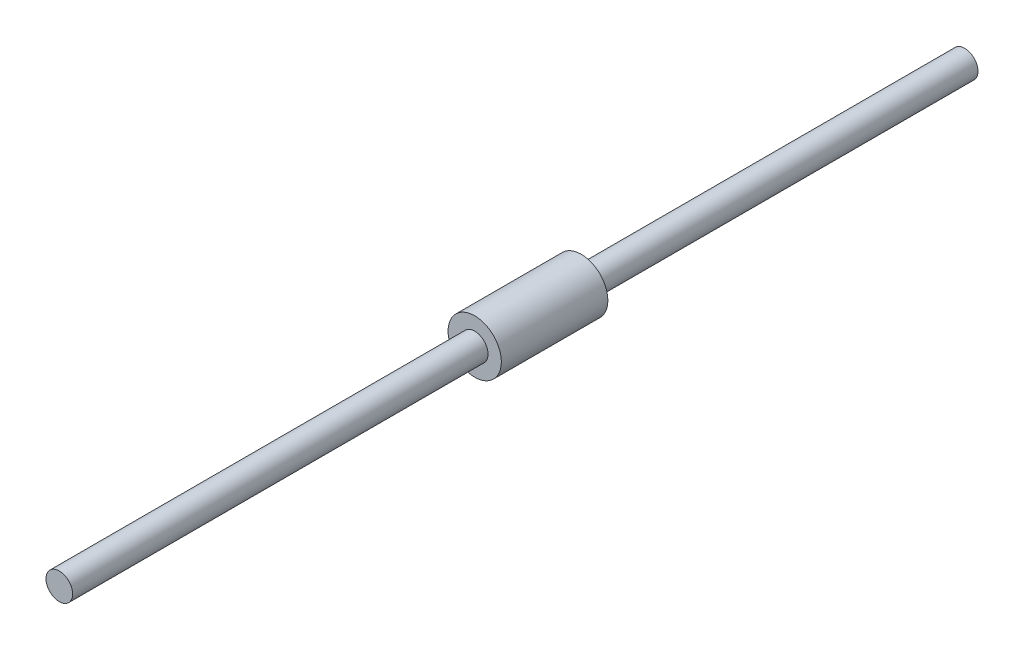
from build123d import *

# Parameters (mm, degrees)
BOSS_EXTRUDE1_DEPTH      = 50
BOSS_EXTRUDE1_DEPTH_BACK = 50
SKETCH1_R                = 25
SKETCH1_R_2              = 12.5
BOSS_EXTRUDE3_DEPTH      = 390
BOSS_EXTRUDE3_DEPTH_BACK = 460
SKETCH3_R                = 12.5


with BuildPart() as part:
    # Sketch1 → Boss-Extrude1 (new, two sides: drawn at the far end of the back side and taken through both)
    with BuildSketch(Plane.XY.offset(-BOSS_EXTRUDE1_DEPTH_BACK)):
        Circle(SKETCH1_R)
        Circle(SKETCH1_R_2, mode=Mode.SUBTRACT)
    extrude(amount=BOSS_EXTRUDE1_DEPTH + BOSS_EXTRUDE1_DEPTH_BACK)

    # Sketch3 → Boss-Extrude3 (add, two sides: drawn at the far end of the back side and taken through both)
    with BuildSketch(Plane.XY.offset(50).offset(-BOSS_EXTRUDE3_DEPTH_BACK)):
        Circle(SKETCH3_R)
    extrude(amount=BOSS_EXTRUDE3_DEPTH + BOSS_EXTRUDE3_DEPTH_BACK)


solid = part.part
